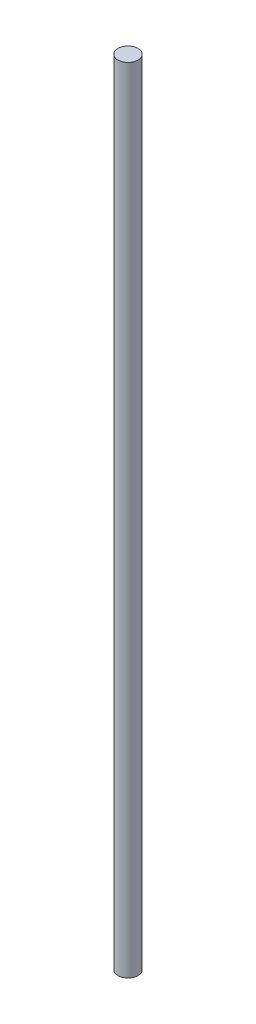
from build123d import *

# Parameters (mm, degrees)
CROQUIS1_R              = 6.35
SALIENTE_EXTRUIR2_DEPTH = 500


with BuildPart() as part:
    # Croquis1 → Saliente-Extruir2 (new body)
    with BuildSketch(Plane(origin=(0, 0, 0), x_dir=(1, 0, 0), z_dir=(0, 1, 0))):
        Circle(CROQUIS1_R)
    extrude(amount=SALIENTE_EXTRUIR2_DEPTH)


solid = part.part
